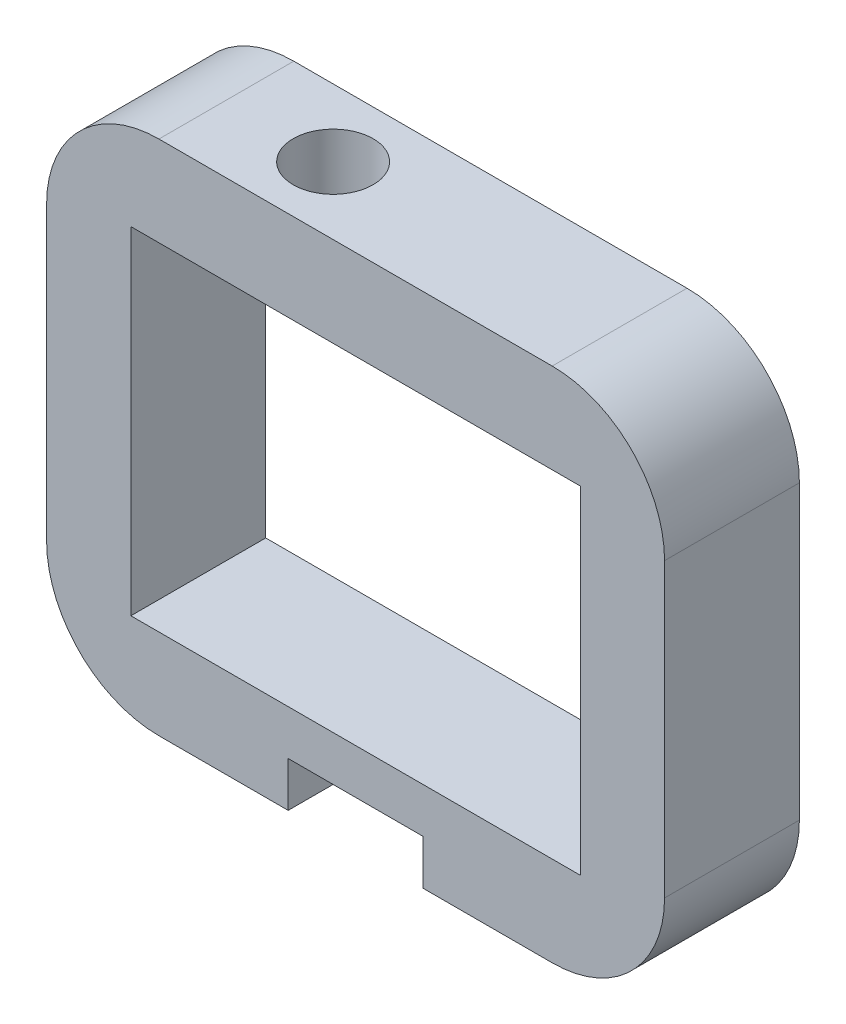
from build123d import *

# Parameters (mm, degrees)
SKETCH1_W           = 55
SKETCH1_H           = 46
SKETCH1_W_2         = 40
SKETCH1_H_2         = 30
BOSS_EXTRUDE1_DEPTH = 6
SKETCH3_R           = 3.556
CUT_EXTRUDE1_DEPTH  = 24
SKETCH6_W           = 12
SKETCH6_H           = 12
CUT_EXTRUDE4_DEPTH  = 4
FILLET1_R           = 10


with BuildPart() as part:
    # Sketch1 → Boss-Extrude1 (new body, symmetric)
    with BuildSketch(Plane.XY):
        Rectangle(SKETCH1_W, SKETCH1_H)
        Rectangle(SKETCH1_W_2, SKETCH1_H_2, mode=Mode.SUBTRACT)
    extrude(amount=BOSS_EXTRUDE1_DEPTH, both=True)

    # Sketch3 → Cut-Extrude1 (cut, through all)
    with BuildSketch(Plane(origin=(0, 0, 0), x_dir=(1, 0, 0), z_dir=(0, 1, 0))):
        with Locations((-8, 0)):
            Circle(SKETCH3_R)
    extrude(amount=CUT_EXTRUDE1_DEPTH, mode=Mode.SUBTRACT)

    # Sketch6 → Cut-Extrude4 (cut)
    with BuildSketch(Plane.XZ.offset(23)):
        Rectangle(SKETCH6_W, SKETCH6_H)
    extrude(amount=-CUT_EXTRUDE4_DEPTH, mode=Mode.SUBTRACT)

    # Fillet1
    fillet1_edges = [part.edges().sort_by_distance(p)[0] for p in [
        (-27.5, -23, 0),
        (-27.5, 23, 0),
        (27.5, 23, 0),
        (27.5, -23, 0),
    ]]
    fillet(fillet1_edges, radius=FILLET1_R)


solid = part.part
